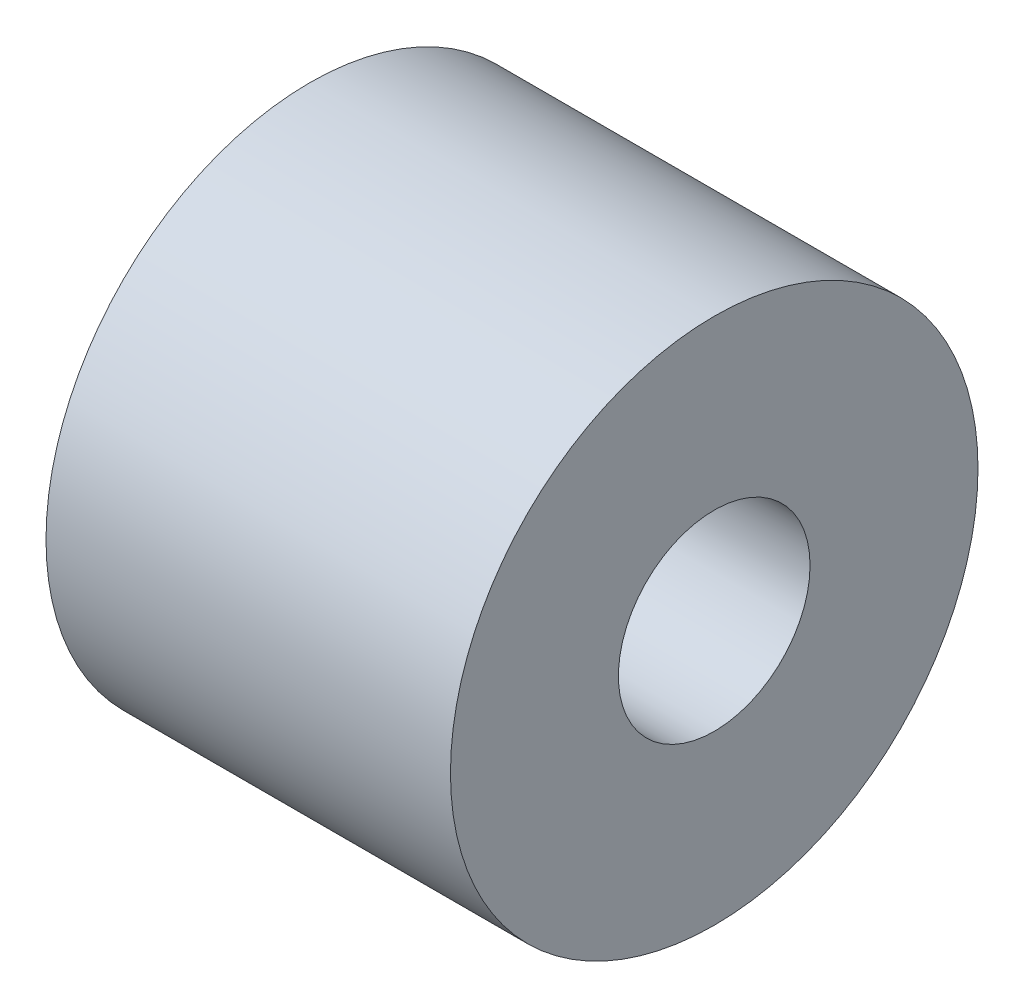
from build123d import *

# Parameters (mm, degrees)
SKETCH1_R           = 30
SKETCH1_R_2         = 9
BOSS_EXTRUDE1_DEPTH = 46
SKETCH2_R           = 10.9
CUT_EXTRUDE1_DEPTH  = 23


with BuildPart() as part:
    # Sketch1 → Boss-Extrude1 (new body)
    with BuildSketch(Plane(origin=(0, 0, 0), x_dir=(0, 0, -1), z_dir=(1, 0, 0))):
        Circle(SKETCH1_R)
        Circle(SKETCH1_R_2, mode=Mode.SUBTRACT)
    extrude(amount=BOSS_EXTRUDE1_DEPTH)

    # Sketch2 → Cut-Extrude1 (cut)
    with BuildSketch(Plane(origin=(46, 0, 0), x_dir=(0, 0, -1), z_dir=(1, 0, 0))):
        Circle(SKETCH2_R)
    extrude(amount=-CUT_EXTRUDE1_DEPTH, mode=Mode.SUBTRACT)


solid = part.part
